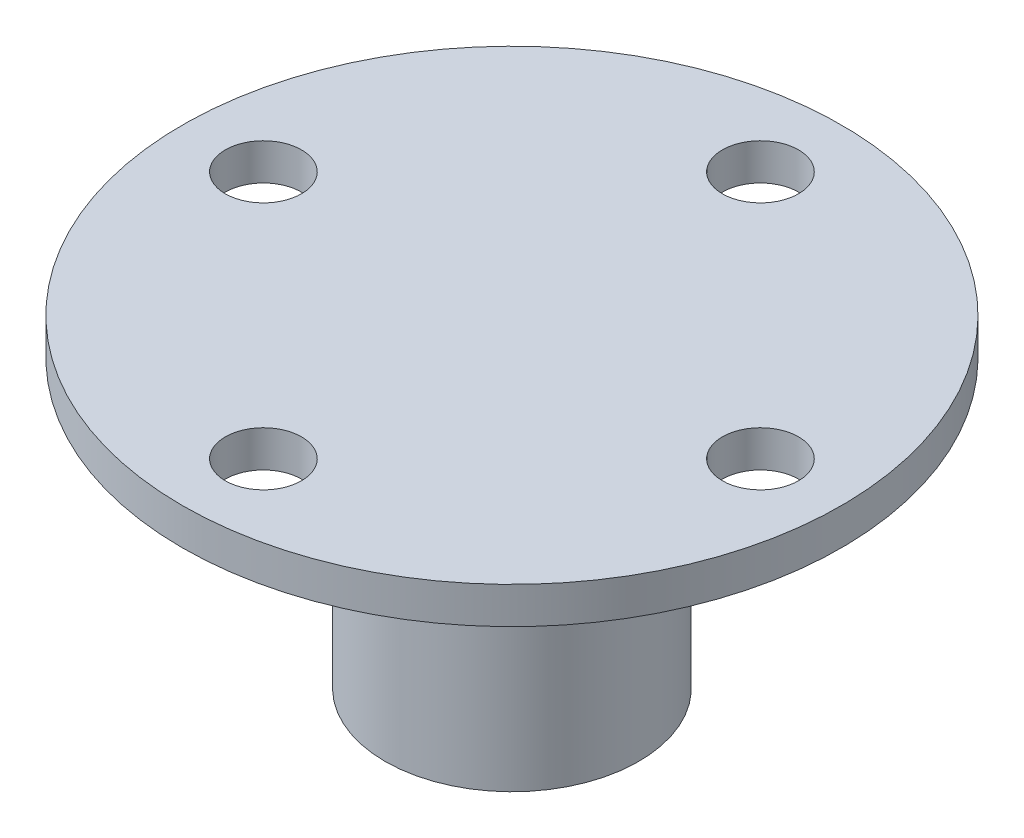
from build123d import *

# Parameters (mm, degrees)
SKETCH1_R           = 28.575
SKETCH1_R_2         = 3.302
SKETCH1_R_3         = 11
BOSS_EXTRUDE1_DEPTH = 3.175
SKETCH1_4_R         = 11
BOSS_EXTRUDE2_DEPTH = 3.175
SKETCH1_5_R         = 11
BOSS_EXTRUDE3_DEPTH = 24.825
FILLET1_R           = 5


with BuildPart() as part:
    # Sketch1 → Boss-Extrude1 (new body)
    with BuildSketch(Plane(origin=(0, 0, 0), x_dir=(1, 0, 0), z_dir=(0, 1, 0))):
        Circle(SKETCH1_R)
        with Locations((0, -21.548)):
            Circle(SKETCH1_R_2, mode=Mode.SUBTRACT)
        with Locations((-21.548, 0)):
            Circle(SKETCH1_R_2, mode=Mode.SUBTRACT)
        Circle(SKETCH1_R_3, mode=Mode.SUBTRACT)
        with BuildLine():
            ThreePointArc((24.85, 0), (21.548, -3.302), (18.246, 0))
            ThreePointArc((18.246, 0), (21.548, 3.302), (24.85, 0))
        make_face(mode=Mode.SUBTRACT)
        with Locations((0, 21.548)):
            Circle(SKETCH1_R_2, mode=Mode.SUBTRACT)
    extrude(amount=BOSS_EXTRUDE1_DEPTH)

    # Sketch1_4 → Boss-Extrude2 (add)
    with BuildSketch(Plane(origin=(0, 0, 0), x_dir=(1, 0, 0), z_dir=(0, 1, 0))):
        Circle(SKETCH1_4_R)
    extrude(amount=BOSS_EXTRUDE2_DEPTH)

    # Sketch1_5 → Boss-Extrude3 (add)
    with BuildSketch(Plane(origin=(0, 0, 0), x_dir=(1, 0, 0), z_dir=(0, 1, 0))):
        Circle(SKETCH1_5_R)
        with BuildLine():
            ThreePointArc((-5.414213562, -2.585786438), (-1.325654296, 5.851721173), (6, 0))
            ThreePointArc((6, 0), (3.200412581, -5.075170865), (-2.585786438, -5.414213562))
            Line((-2.585786438, -5.414213562), (-3.889087297, -6.717514421))
            Line((-3.889087297, -6.717514421), (-6.717514421, -3.889087297))
            Line((-6.717514421, -3.889087297), (-5.414213562, -2.585786438))
        make_face(mode=Mode.SUBTRACT)
    extrude(amount=-BOSS_EXTRUDE3_DEPTH)

    # Fillet1
    fillet1_edges = [part.edges().sort_by_distance(p)[0] for p in [
        (-11, 0, 0),
    ]]
    fillet(fillet1_edges, radius=FILLET1_R)


solid = part.part
